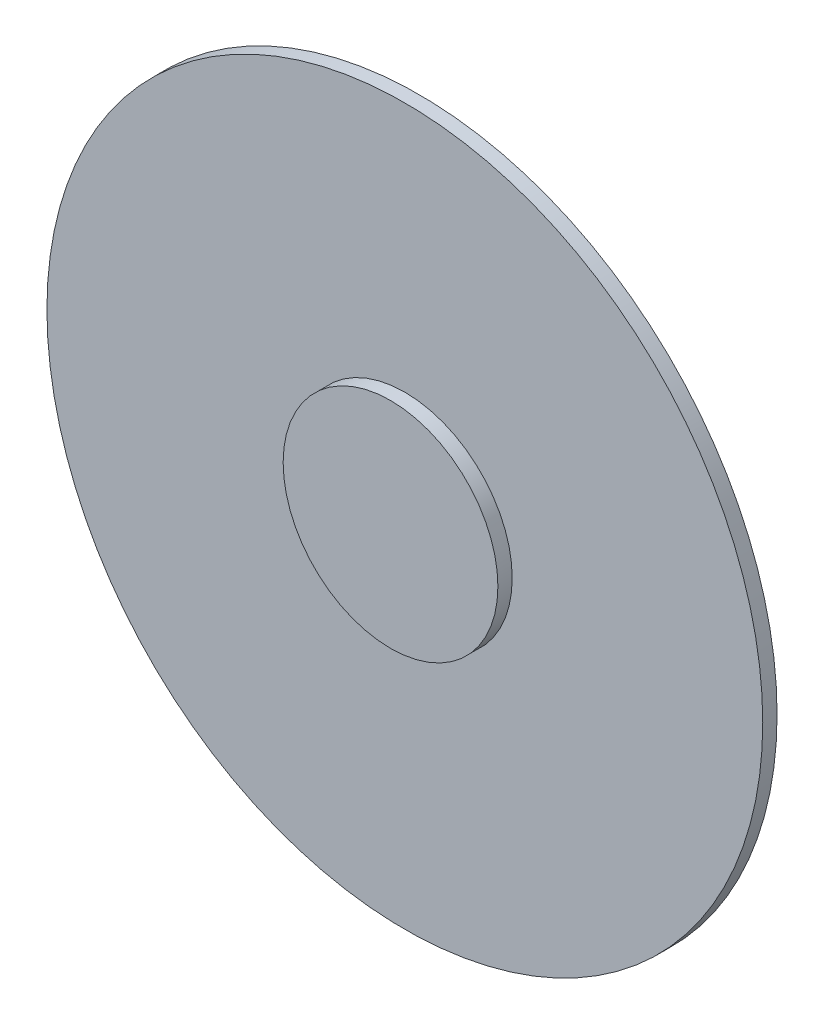
from build123d import *

# Parameters (mm, degrees)
SKETCH_1_R      = 25
EXTRUDE_1_DEPTH = 1
SKETCH_3_R      = 25
SKETCH_2_R      = 10
SKETCH_4_R      = 7.5
EXTRUDE_2_DEPTH = 1


with BuildPart() as part:
    # 草图1 → 凸台-拉伸1 (new body)
    with BuildSketch(Plane.XY):
        Circle(SKETCH_1_R)
    extrude(amount=EXTRUDE_1_DEPTH)

    # 草图3 → 放样1 section 0
    with BuildSketch(Plane(origin=(0, 0, 0), x_dir=(-1, 0, 0), z_dir=(0, 0, -1))):
        Circle(SKETCH_3_R)
    # 草图2 → 放样1 section 1
    with BuildSketch(Plane(origin=(0, 0, -5), x_dir=(-1, 0, 0), z_dir=(0, 0, -1))):
        Circle(SKETCH_2_R)
    loft()

    # 草图4 → 凸台-拉伸2 (add)
    with BuildSketch(Plane.XY.offset(1)):
        Circle(SKETCH_4_R)
    extrude(amount=EXTRUDE_2_DEPTH)


solid = part.part
